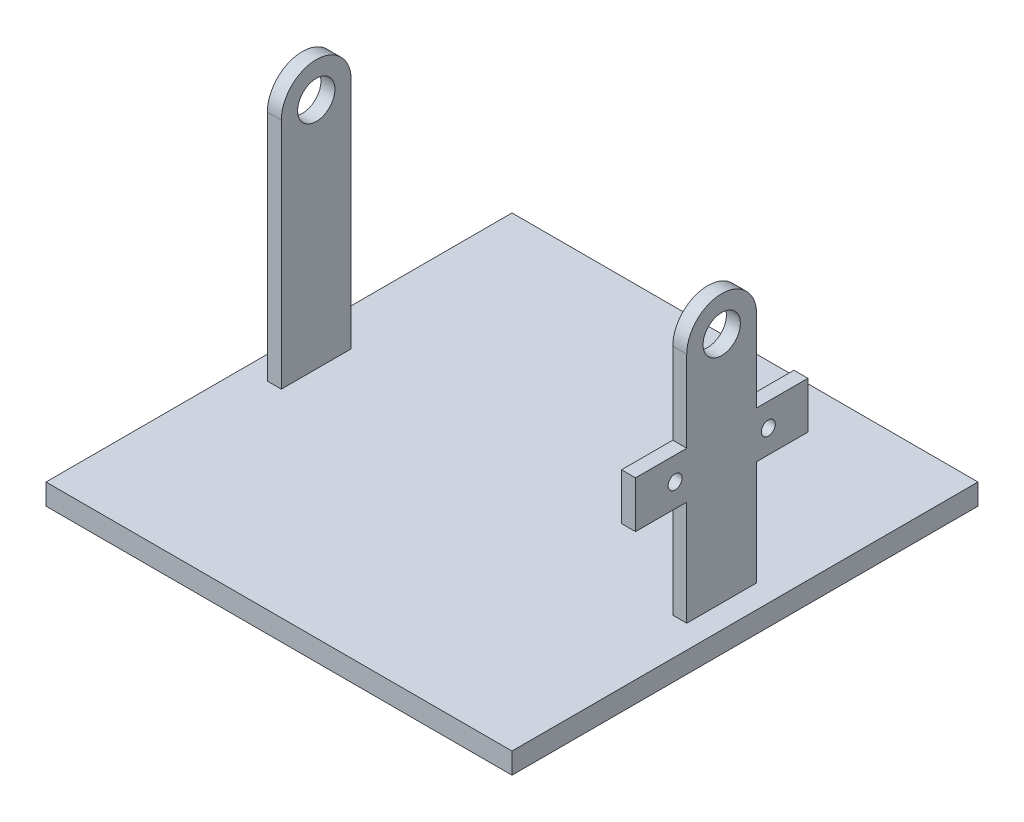
from build123d import *

# Parameters (mm, degrees)
SKETCH1_W           = 100
SKETCH1_H           = 100
BOSS_EXTRUDE1_DEPTH = 4.5
SKETCH2_W           = 3
SKETCH2_H           = 15
BOSS_EXTRUDE2_DEPTH = 60
SKETCH3_R           = 4
CUT_EXTRUDE1_DEPTH  = 96
SKETCH4_R           = 1.5
BOSS_EXTRUDE3_DEPTH = 3


with BuildPart() as part:
    # Sketch1 → Boss-Extrude1 (new body)
    with BuildSketch(Plane(origin=(0, 0, 0), x_dir=(1, 0, 0), z_dir=(0, 1, 0))):
        Rectangle(SKETCH1_W, SKETCH1_H)
    extrude(amount=BOSS_EXTRUDE1_DEPTH)

    # Sketch2 → Boss-Extrude2 (add)
    with BuildSketch(Plane(origin=(0, 4.5, 0), x_dir=(1, 0, 0), z_dir=(0, 1, 0))):
        with Locations((43.5, 0)):
            Rectangle(SKETCH2_W, SKETCH2_H)
        with Locations((-43.5, 0)):
            Rectangle(SKETCH2_W, SKETCH2_H)
    extrude(amount=BOSS_EXTRUDE2_DEPTH)

    # Sketch3 → Cut-Extrude1 (cut, through all)
    with BuildSketch(Plane(origin=(45, 0, 0), x_dir=(0, 0, -1), z_dir=(1, 0, 0))):
        with Locations((0, 54.5)):
            Circle(SKETCH3_R)
        with BuildLine():
            Line((-7.5, 54.5), (-7.5, 64.5))
            Line((-7.5, 64.5), (7.5, 64.5))
            Line((7.5, 64.5), (7.5, 54.5))
            ThreePointArc((7.5, 54.5), (0, 62), (-7.5, 54.5))
        make_face()
    extrude(amount=-CUT_EXTRUDE1_DEPTH, mode=Mode.SUBTRACT)

    # Sketch4 → Boss-Extrude3 (add)
    with BuildSketch(Plane(origin=(45, 0, 0), x_dir=(0, 0, -1), z_dir=(1, 0, 0))):
        Polygon((0, 27.02), (18.5, 27.02), (18.5, 37.02), (-18.5, 37.02), (-18.5, 27.02), align=None)
        with Locations((-10, 32.02)):
            Circle(SKETCH4_R, mode=Mode.SUBTRACT)
        with Locations((10, 32.02)):
            Circle(SKETCH4_R, mode=Mode.SUBTRACT)
    extrude(amount=-BOSS_EXTRUDE3_DEPTH)


solid = part.part
